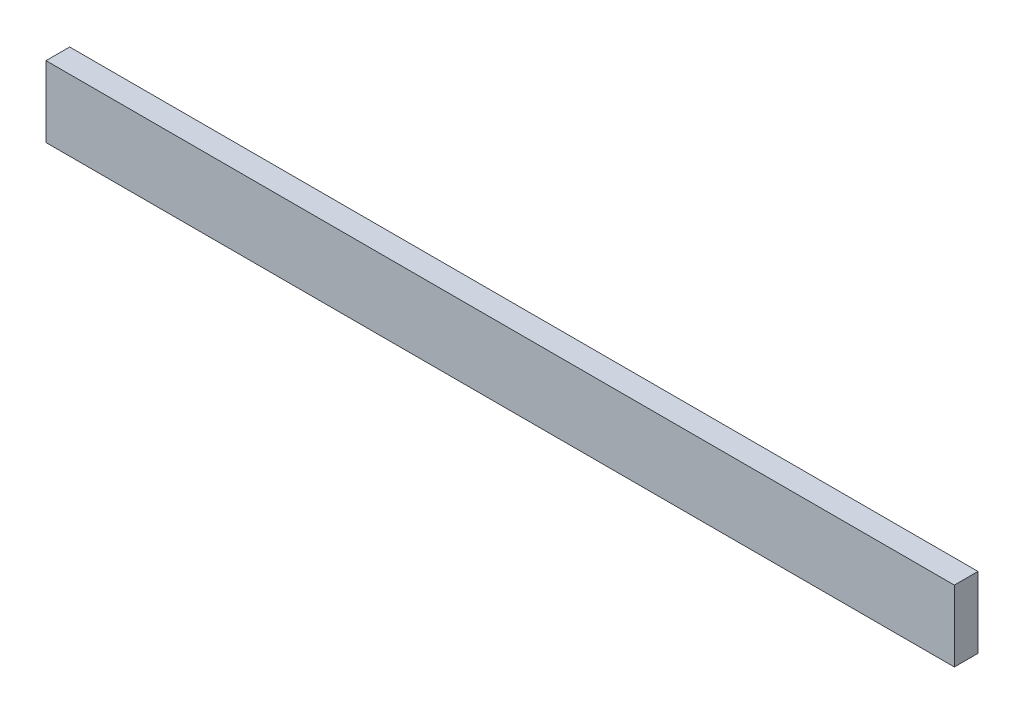
from build123d import *

# Parameters (mm, degrees)
SKETCH2_W           = 243.84
SKETCH2_H           = 19.05
BOSS_EXTRUDE1_DEPTH = 6.35


with BuildPart() as part:
    # Sketch2 → Boss-Extrude1 (new body)
    with BuildSketch(Plane.XY):
        with Locations((121.92, 9.525)):
            Rectangle(SKETCH2_W, SKETCH2_H)
    extrude(amount=BOSS_EXTRUDE1_DEPTH)


solid = part.part
